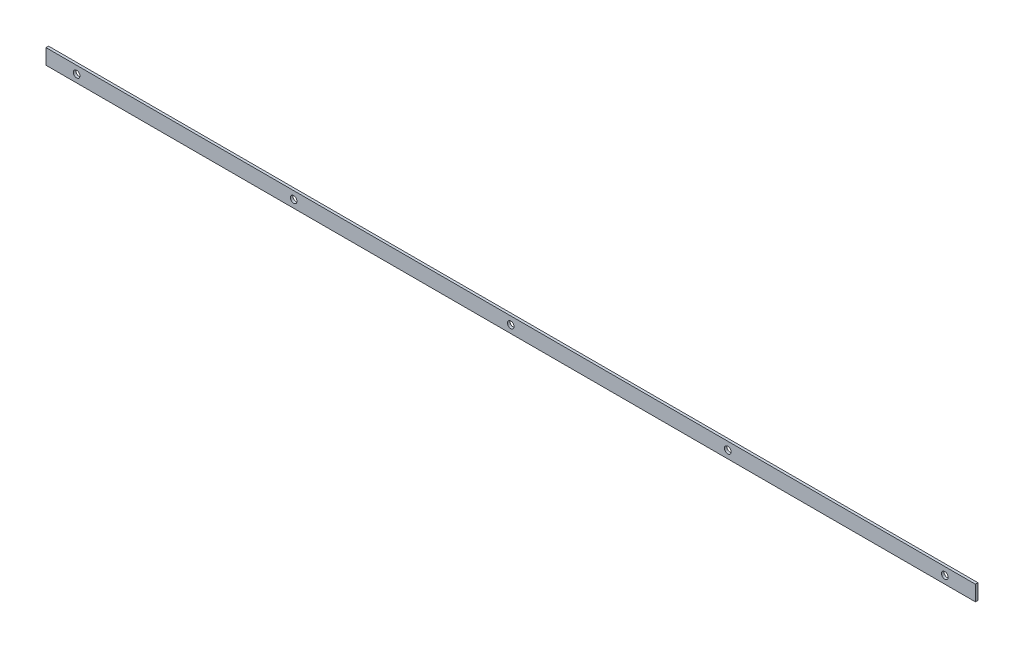
from build123d import *

# Parameters (mm, degrees)
PLAT_W                          = 30
PLAT_H                          = 5
EL_MENT_M_CANO_SOUD_1_DEPTH     = 1820
DIAM_TRE_DU_PER_AGE_13_0_13_1_D = 13
R_P_TITION_LIN_AIRE2_COUNT      = 5
R_P_TITION_LIN_AIRE2_PITCH      = 425


with BuildPart() as part:
    # plat → Elément mécano-soudé1 (new body)
    with BuildSketch(Plane.YZ.offset(-910)):
        Rectangle(PLAT_W, PLAT_H)
    extrude(amount=EL_MENT_M_CANO_SOUD_1_DEPTH)

    # Diamètre du perçage Ø13.0 (13)1 (through all)
    with Locations(Plane(origin=(0, 0, -2.5), x_dir=(-1, 0, 0), z_dir=(0, 0, -1))):
        with Locations((850, 0)):
            diam_tre_du_per_age_13_0_13_1 = Hole(DIAM_TRE_DU_PER_AGE_13_0_13_1_D / 2)

    # Répétition linéaire2: Diamètre du perçage Ø13.0 (13)1 ×5
    with Locations(*[(i * R_P_TITION_LIN_AIRE2_PITCH, 0, 0) for i in range(1, R_P_TITION_LIN_AIRE2_COUNT)]):
        add(diam_tre_du_per_age_13_0_13_1, mode=Mode.SUBTRACT)


solid = part.part
